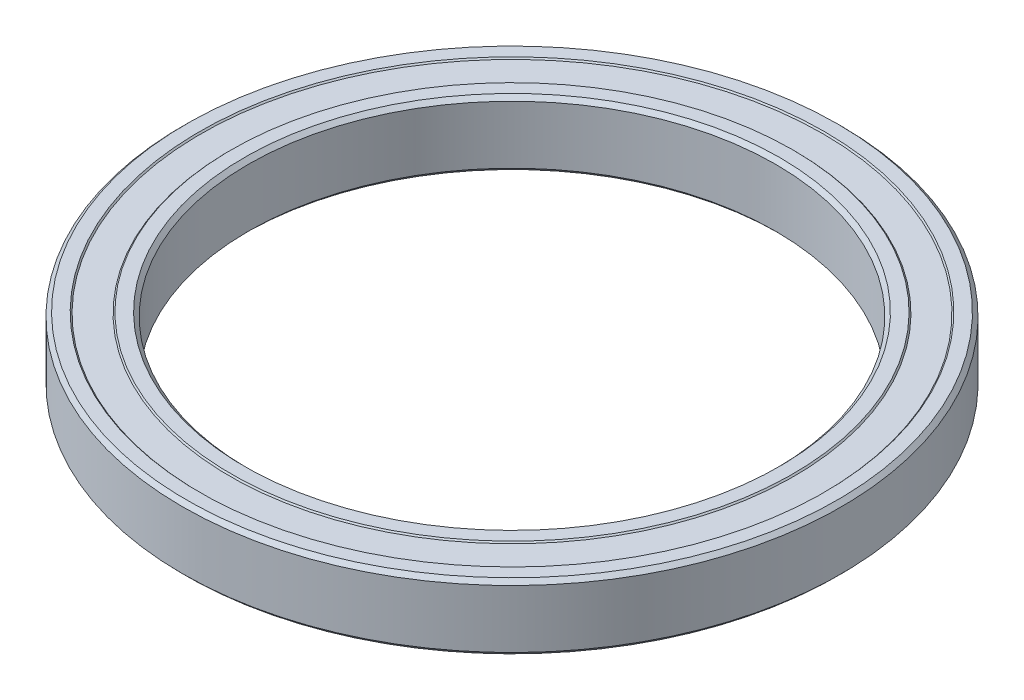
from build123d import *


with BuildPart() as part:
    # Sketch1 → Revolve1 (revolve)
    with BuildSketch(Plane.XY):
        Polygon((40, 4.4), (40, -4.4), (40.6, -5), (42.6, -5), (42.8, -4.8), (47.2, -4.8), (47.4, -5), (49.4, -5), (50, -4.4), (50, 4.4), (49.4, 5), (47.4, 5), (47.2, 4.8), (42.8, 4.8), (42.6, 5), (40.6, 5), align=None)
    revolve(axis=Axis((0, -1.349421972, 0), (0, 1, 0)))


solid = part.part
